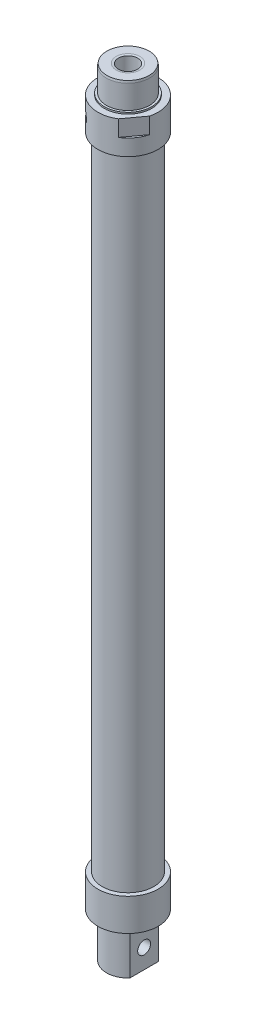
from build123d import *
from OCP.BRepFilletAPI import BRepFilletAPI_MakeChamfer

# Parameters (mm, degrees)
SKETCH1_R           = 12
SKETCH1_R_2         = 10
BOSS_EXTRUDE1_DEPTH = 298
SKETCH2_R           = 14
SKETCH2_R_2         = 10
BOSS_EXTRUDE2_DEPTH = 15
SKETCH4_W           = 12
SKETCH4_H           = 7.5
CUT_EXTRUDE1_DEPTH  = 1
SKETCH5_R           = 2.5
CUT_EXTRUDE2_DEPTH  = 5
SKETCH6_R           = 11
BOSS_EXTRUDE3_DEPTH = 0.75
SKETCH7_R           = 10
BOSS_EXTRUDE4_DEPTH = 12
SKETCH9_R           = 14
SKETCH9_R_2         = 10
BOSS_EXTRUDE6_DEPTH = 15
SKETCH10_R          = 11
BOSS_EXTRUDE7_DEPTH = 0.75
SKETCH11_R          = 10
BOSS_EXTRUDE8_DEPTH = 20
CUT_EXTRUDE4_DEPTH  = 20
SKETCH13_R          = 3
CUT_EXTRUDE5_DEPTH  = 327.758798668
SKETCH14_R          = 4.5
CUT_EXTRUDE6_DEPTH  = 70
CHAMFER1_SIZE       = 1
CHAMFER1_SIZE2      = 0.176326981


with BuildPart() as part:
    # Sketch1 → Boss-Extrude1 (new body)
    with BuildSketch(Plane(origin=(0, 0, 0), x_dir=(1, 0, 0), z_dir=(0, 1, 0))):
        with Locations(Location((0, 0, 0), (0, 0, 270))):
            Circle(SKETCH1_R)
        with Locations(Location((0, 0, 0), (0, 0, 270))):
            Circle(SKETCH1_R_2, mode=Mode.SUBTRACT)
    extrude(amount=BOSS_EXTRUDE1_DEPTH)

    # Sketch2 → Boss-Extrude2 (add)
    with BuildSketch(Plane(origin=(0, 298, 0), x_dir=(1, 0, 0), z_dir=(0, 1, 0))):
        with Locations(Location((0, 0, 0), (0, 0, 270))):
            Circle(SKETCH2_R)
        with Locations(Location((0, 0, 0), (0, 0, 270))):
            Circle(SKETCH2_R_2, mode=Mode.SUBTRACT)
    extrude(amount=BOSS_EXTRUDE2_DEPTH)

    # Sketch4 → Cut-Extrude1 (cut)
    with BuildSketch(Plane(origin=(11.289405747, 313, 8.279451545), x_dir=(0.5913893960477971, 0, -0.8063861247828004), z_dir=(0.8063861247828003, 0, 0.591389396047797))):
        with Locations((0, -3.75)):
            Rectangle(SKETCH4_W, SKETCH4_H)
    cut_extrude1 = extrude(amount=-CUT_EXTRUDE1_DEPTH, mode=Mode.SUBTRACT)

    # Mirror1: Cut-Extrude1 across plane
    add(cut_extrude1.mirror(Plane(origin=(0, 313, 0), x_dir=(-0.5913893960477972, 0, 0.8063861247828003), z_dir=(0.8063861247828004, 0, 0.5913893960477971))), mode=Mode.SUBTRACT)

    # Sketch5 → Cut-Extrude2 (cut)
    with BuildSketch(Plane(origin=(-9.547499861, 313, 10.239396779), x_dir=(0.7313854842378409, 0, 0.6819642757844279), z_dir=(-0.6819642757844279, 0, 0.7313854842378409))):
        with Locations((0, -8)):
            Circle(SKETCH5_R)
    extrude(amount=-CUT_EXTRUDE2_DEPTH, mode=Mode.SUBTRACT)

    # Sketch6 → Boss-Extrude3 (add)
    with BuildSketch(Plane(origin=(0, 313, 0), x_dir=(1, 0, 0), z_dir=(0, 1, 0))):
        with Locations(Location((0, 0, 0), (0, 0, 270))):
            Circle(SKETCH6_R)
    extrude(amount=BOSS_EXTRUDE3_DEPTH)

    # Sketch7 → Boss-Extrude4 (add)
    with BuildSketch(Plane(origin=(0, 313.75, 0), x_dir=(1, 0, 0), z_dir=(0, 1, 0))):
        with Locations(Location((0, 0, 0), (0, 0, 270))):
            Circle(SKETCH7_R)
    extrude(amount=BOSS_EXTRUDE4_DEPTH)

    # Sketch9 → Boss-Extrude6 (add)
    with BuildSketch(Plane.XZ):
        with Locations(Location((0, 0, 0), (0, 0, 238.042455368))):
            Circle(SKETCH9_R)
        with Locations(Location((0, 0, 0), (0, 0, 270))):
            Circle(SKETCH9_R_2, mode=Mode.SUBTRACT)
    extrude(amount=BOSS_EXTRUDE6_DEPTH)

    # Sketch10 → Boss-Extrude7 (add)
    with BuildSketch(Plane.XZ.offset(15)):
        with Locations(Location((0, 0, 0), (0, 0, 90))):
            Circle(SKETCH10_R)
    extrude(amount=BOSS_EXTRUDE7_DEPTH)

    # Sketch11 → Boss-Extrude8 (add)
    with BuildSketch(Plane.XZ.offset(15.75)):
        with Locations(Location((0, 0, 0), (0, 0, 270))):
            Circle(SKETCH11_R)
    extrude(amount=BOSS_EXTRUDE8_DEPTH)

    # Sketch12 → Cut-Extrude4 (cut)
    with BuildSketch(Plane.XZ.offset(35.75)):
        with BuildLine():
            Line((-7.5, -6.614378278), (-7.5, 6.614378278))
            ThreePointArc((-7.5, 6.614378278), (-10, 0), (-7.5, -6.614378278))
        make_face()
        with BuildLine():
            ThreePointArc((10, 0), (9.354143467, 3.535533906), (7.5, 6.614378278))
            Line((7.5, 6.614378278), (7.5, -6.614378278))
            ThreePointArc((7.5, -6.614378278), (9.354143467, -3.535533906), (10, 0))
        make_face()
    extrude(amount=-CUT_EXTRUDE4_DEPTH, mode=Mode.SUBTRACT)

    # Sketch13 → Cut-Extrude5 (cut, through all)
    with BuildSketch(Plane(origin=(7.5, 0, 0), x_dir=(0, 0, -1), z_dir=(1, 0, 0))):
        with Locations((0, -26.75)):
            Circle(SKETCH13_R)
    extrude(amount=-CUT_EXTRUDE5_DEPTH, mode=Mode.SUBTRACT)

    # Sketch14 → Cut-Extrude6 (cut)
    with BuildSketch(Plane(origin=(0, 325.75, 0), x_dir=(1, 0, 0), z_dir=(0, 1, 0))):
        with Locations(Location((0, 0, 0), (0, 0, 270))):
            Circle(SKETCH14_R)
    extrude(amount=-CUT_EXTRUDE6_DEPTH, mode=Mode.SUBTRACT)

    # Chamfer1: one chamfer whose edges measure the first distance from different faces: ONE call of the kernel's chamfer builder (chamfer() names one face for all edges)
    chamfer1_edges_1 = [part.edges().sort_by_distance(p)[0] for p in [
        (0, 313, -4.5),
    ]]
    chamfer1_side_1 = [part.faces().sort_by_distance(p)[0] for p in [
        (0, 319.375, -4.5),
    ]]
    chamfer1_edges_2 = [part.edges().sort_by_distance(p)[0] for p in [
        (0, 325.75, -4.5),
    ]]
    chamfer1_side_2 = [part.faces().sort_by_distance(p)[0] for p in [
        (0, 325.75, -9.717157288),
    ]]
    chamfer1_edges_3 = [part.edges().sort_by_distance(p)[0] for p in [
        (0, 325.75, -10),
    ]]
    chamfer1_side_3 = [part.faces().sort_by_distance(p)[0] for p in [
        (0, 319.75, -10),
    ]]
    chamfer1 = BRepFilletAPI_MakeChamfer(part.part.solid().wrapped)
    for e in chamfer1_edges_1:
        chamfer1.Add(CHAMFER1_SIZE, CHAMFER1_SIZE2, e.wrapped, chamfer1_side_1[0].wrapped)  # the first distance lies on this face
    for e in chamfer1_edges_2:
        chamfer1.Add(CHAMFER1_SIZE, CHAMFER1_SIZE2, e.wrapped, chamfer1_side_2[0].wrapped)  # the first distance lies on this face
    for e in chamfer1_edges_3:
        chamfer1.Add(CHAMFER1_SIZE, CHAMFER1_SIZE2, e.wrapped, chamfer1_side_3[0].wrapped)  # the first distance lies on this face
    add(Compound.cast(chamfer1.Shape()), mode=Mode.REPLACE)


solid = part.part
